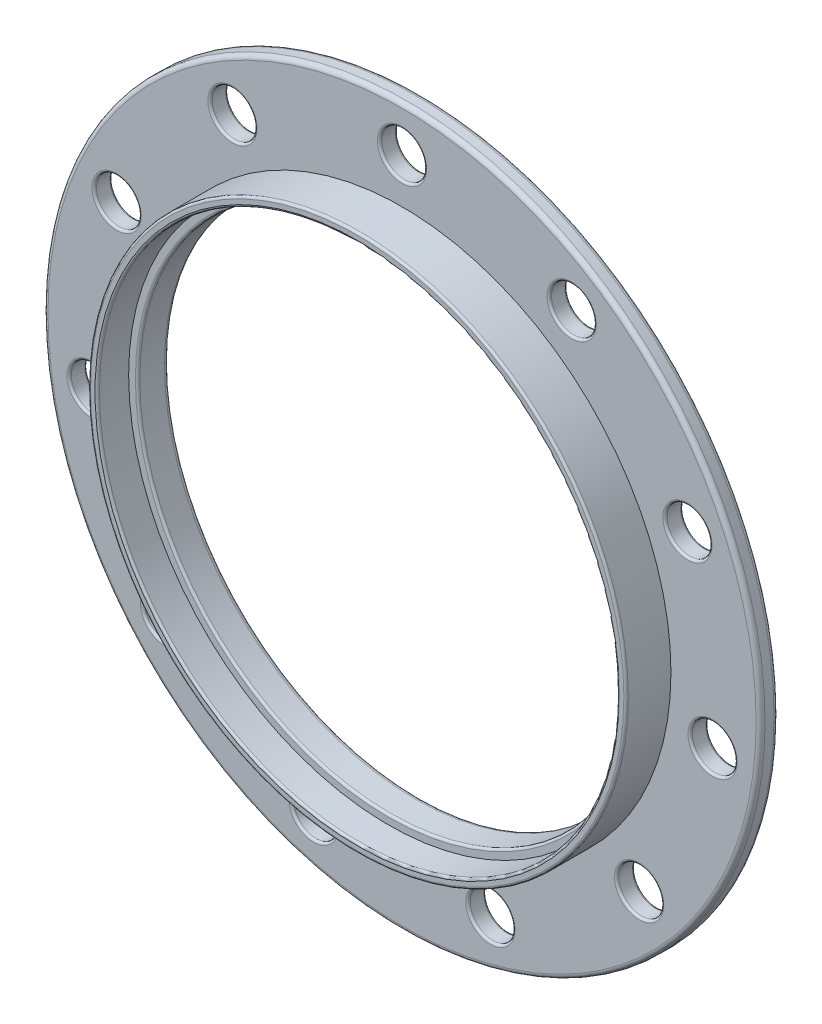
from build123d import *

# Parameters (mm, degrees)
SKETCH1_R           = 40
BOSS_EXTRUDE1_DEPTH = 2
SKETCH2_R           = 30
SKETCH2_R_2         = 29
BOSS_EXTRUDE2_DEPTH = 5
SKETCH3_R           = 29
CUT_EXTRUDE1_DEPTH  = 3
SKETCH4_R           = 2.5
CUT_EXTRUDE2_DEPTH  = 3
SKETCH5_R           = 29
SKETCH5_R_2         = 28
BOSS_EXTRUDE3_DEPTH = 3.5
FILLET1_R           = 0.25
FILLET2_R           = 0.5
FILLET3_R           = 0.25


with BuildPart() as part:
    # Sketch1 → Boss-Extrude1 (new body)
    with BuildSketch(Plane.XY):
        Circle(SKETCH1_R)
    extrude(amount=BOSS_EXTRUDE1_DEPTH)

    # Sketch2 → Boss-Extrude2 (add)
    with BuildSketch(Plane.XY.offset(2)):
        Circle(SKETCH2_R)
        Circle(SKETCH2_R_2, mode=Mode.SUBTRACT)
    extrude(amount=BOSS_EXTRUDE2_DEPTH)

    # Sketch3 → Cut-Extrude1 (cut, through all)
    with BuildSketch(Plane.XY.offset(2)):
        Circle(SKETCH3_R)
    extrude(amount=-CUT_EXTRUDE1_DEPTH, mode=Mode.SUBTRACT)

    # Sketch4 → Cut-Extrude2 (cut, through all)
    with BuildSketch(Plane.XY.offset(2)):
        with Locations((0, 35)):
            Circle(SKETCH4_R)
        with Locations((18.922428611, 29.443873649)):
            Circle(SKETCH4_R)
        with Locations((31.837119837, 14.539525455)):
            Circle(SKETCH4_R)
        with Locations((34.643750466, -4.98101934)):
            Circle(SKETCH4_R)
        with Locations((26.451235102, -22.920125688)):
            Circle(SKETCH4_R)
        with Locations((9.860639489, -33.582254077)):
            Circle(SKETCH4_R)
        with Locations((-9.860639489, -33.582254077)):
            Circle(SKETCH4_R)
        with Locations((-26.451235102, -22.920125688)):
            Circle(SKETCH4_R)
        with Locations((-34.643750466, -4.98101934)):
            Circle(SKETCH4_R)
        with Locations((-31.837119837, 14.539525455)):
            Circle(SKETCH4_R)
        with Locations((-18.922428611, 29.443873649)):
            Circle(SKETCH4_R)
    extrude(amount=-CUT_EXTRUDE2_DEPTH, mode=Mode.SUBTRACT)

    # Sketch5 → Boss-Extrude3 (add)
    with BuildSketch(Plane(origin=(0, 0, 0), x_dir=(-1, 0, 0), z_dir=(0, 0, -1))):
        Circle(SKETCH5_R)
        Circle(SKETCH5_R_2, mode=Mode.SUBTRACT)
    extrude(amount=-BOSS_EXTRUDE3_DEPTH)

    # Fillet1
    fillet1_edges = [part.edges().sort_by_distance(p)[0] for p in [
        (28, 0, 3.5),
        (-30, 0, 7),
        (-29, 0, 7),
    ]]
    fillet(fillet1_edges, radius=FILLET1_R)

    # Fillet2
    fillet2_edges = [part.edges().sort_by_distance(p)[0] for p in [
        (-40, 0, 0),
        (-40, 0, 2),
        (28, 0, 0),
    ]]
    fillet(fillet2_edges, radius=FILLET2_R)

    # Fillet3
    fillet3_edges = [part.edges().sort_by_distance(p)[0] for p in [
        (-2.5, 35, 0),
        (-2.5, 35, 2),
        (-21.422428611, 29.443873649, 0),
        (-21.422428611, 29.443873649, 2),
        (-34.337119837, 14.539525455, 0),
        (-34.337119837, 14.539525455, 2),
        (-37.143750466, -4.98101934, 0),
        (-37.143750466, -4.98101934, 2),
        (-28.951235102, -22.920125688, 0),
        (-28.951235102, -22.920125688, 2),
        (-12.360639489, -33.582254077, 0),
        (-12.360639489, -33.582254077, 2),
        (7.360639489, -33.582254077, 0),
        (7.360639489, -33.582254077, 2),
        (23.951235102, -22.920125688, 0),
        (23.951235102, -22.920125688, 2),
        (32.143750466, -4.98101934, 0),
        (32.143750466, -4.98101934, 2),
        (29.337119837, 14.539525455, 0),
        (29.337119837, 14.539525455, 2),
        (16.422428611, 29.443873649, 0),
        (16.422428611, 29.443873649, 2),
    ]]
    fillet(fillet3_edges, radius=FILLET3_R)


solid = part.part
